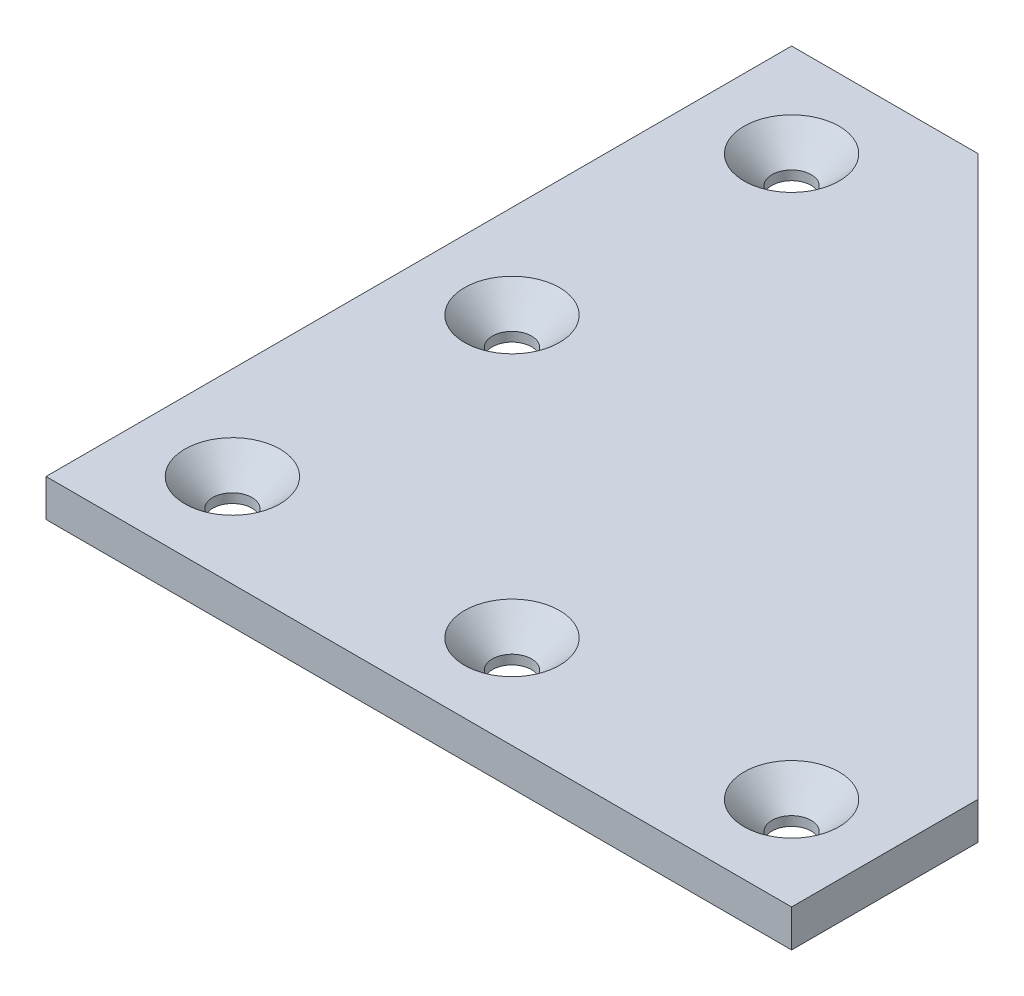
from build123d import *

# Parameters (mm, degrees)
BOSS_EXTRUDE1_DEPTH = 4
SKETCH3_R           = 2.1
CUT_EXTRUDE1_DEPTH  = 4
CHAMFER1_SIZE       = 3


with BuildPart() as part:
    # Sketch1 → Boss-Extrude1 (new body)
    with BuildSketch(Plane(origin=(0, 0, 0), x_dir=(1, 0, 0), z_dir=(0, 1, 0))):
        Polygon((0, 0), (0, 80), (20, 80), (80, 20), (80, 0), align=None)
    extrude(amount=BOSS_EXTRUDE1_DEPTH)

    # Sketch3 → Cut-Extrude1 (cut)
    with BuildSketch(Plane(origin=(0, 4, 0), x_dir=(1, 0, 0), z_dir=(0, 1, 0))):
        with Locations((10, 10)):
            Circle(SKETCH3_R)
        with Locations((40, 10)):
            Circle(SKETCH3_R)
        with Locations((70, 10)):
            Circle(SKETCH3_R)
        with Locations((10, 40)):
            Circle(SKETCH3_R)
        with Locations((10, 70)):
            Circle(SKETCH3_R)
    extrude(amount=-CUT_EXTRUDE1_DEPTH, mode=Mode.SUBTRACT)

    # Chamfer1
    chamfer1_edges = [part.edges().sort_by_distance(p)[0] for p in [
        (7.9, 4, -70),
        (7.9, 4, -40),
        (67.9, 4, -10),
        (7.9, 4, -10),
        (37.9, 4, -10),
    ]]
    chamfer(chamfer1_edges, length=CHAMFER1_SIZE)


solid = part.part
